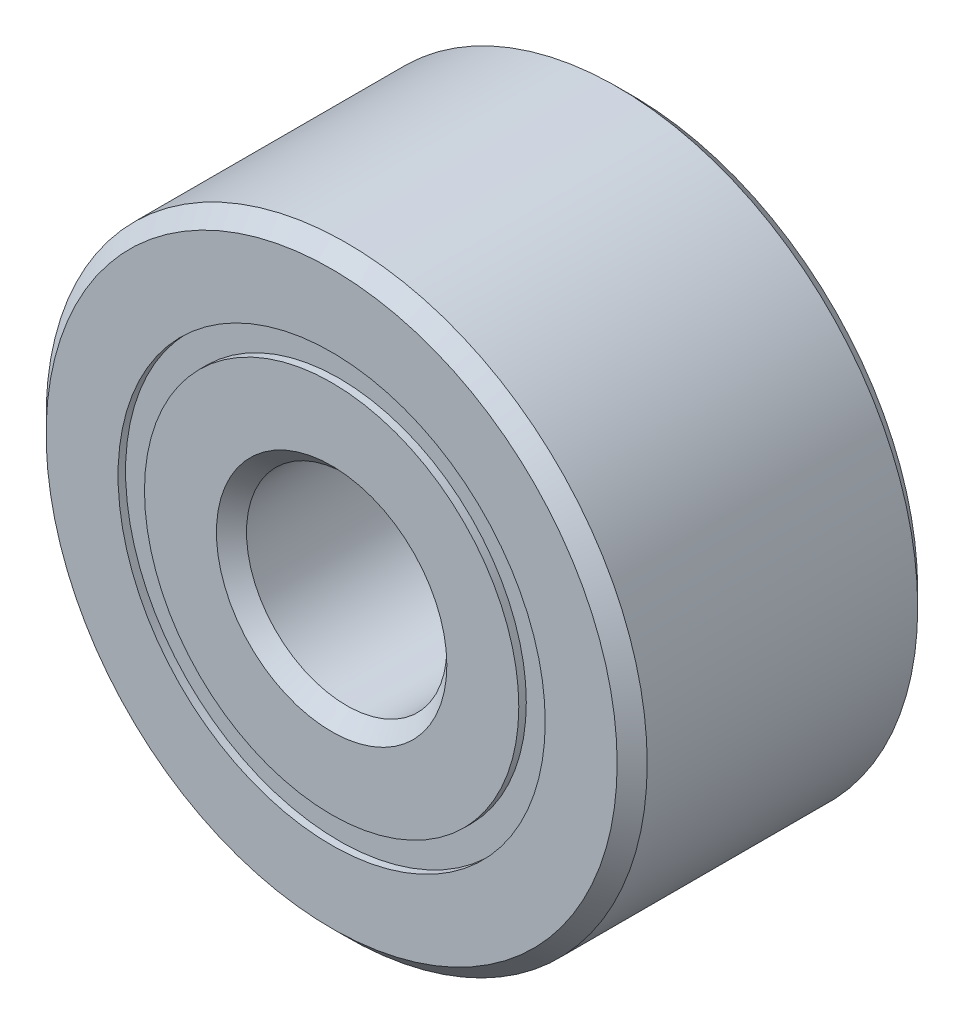
from build123d import *

# Parameters (mm, degrees)
CIRPATTERN1_COUNT = 12
SKETCH5_W         = 0.745416562
SKETCH5_H         = 0.263736264


with BuildPart() as part:
    # Sketch1 → Revolve1 (revolve)
    with BuildSketch(Plane(origin=(0, 0, 0), x_dir=(0, 0, -1), z_dir=(1, 0, 0))):
        with BuildLine():
            Line((1.35, 3), (-1.35, 3))
            Line((-1.35, 3), (-1.5, 2.85))
            Line((-1.5, 2.85), (-1.5, 2.131868132))
            Line((-1.5, 2.131868132), (-0.666666667, 2.131868132))
            ThreePointArc((-0.666666667, 2.131868132), (0, 2.679583438), (0.666666667, 2.131868132))
            Line((0.666666667, 2.131868132), (1.5, 2.131868132))
            Line((1.5, 2.131868132), (1.5, 2.85))
            Line((1.5, 2.85), (1.35, 3))
        make_face()
    revolve(axis=Axis((0, 0, 1.5), (0, 0, -1)))


with BuildPart() as body_2:
    # Sketch3 → Revolve3 (revolve)
    with BuildSketch(Plane(origin=(0, 0, 0), x_dir=(0, 0, -1), z_dir=(1, 0, 0))):
        with BuildLine():
            Line((-1.5, 1.868131868), (-0.666666667, 1.868131868))
            ThreePointArc((-0.666666667, 1.868131868), (0, 1.320416562), (0.666666667, 1.868131868))
            Line((0.666666667, 1.868131868), (1.5, 1.868131868))
            Line((1.5, 1.868131868), (1.5, 1.15))
            Line((1.5, 1.15), (1.35, 1))
            Line((1.35, 1), (-1.35, 1))
            Line((-1.35, 1), (-1.5, 1.15))
            Line((-1.5, 1.15), (-1.5, 1.868131868))
        make_face()
    revolve(axis=Axis((0, 0, 1.5), (0, 0, -1)))


with BuildPart() as body_3:
    # Sketch4 → Revolve4 (revolve)
    with BuildSketch(Plane(origin=(0, 0, 0), x_dir=(0, 0, -1), z_dir=(1, 0, 0))):
        with BuildLine():
            Line((-0.679583438, 2), (0.679583438, 2))
            ThreePointArc((0.679583438, 2), (0, 2.679583438), (-0.679583438, 2))
        make_face()
    revolve(axis=Axis((0, 2, 0.679583438), (0, 0, -1)))


with BuildPart() as cirpattern1_1:
    # CirPattern1: pattern copy
    add(body_3.part.rotate(Axis((0, 0, 0), (0, 0, 1)), 1 * 360 / CIRPATTERN1_COUNT))


with BuildPart() as cirpattern1_2:
    # CirPattern1: pattern copy
    add(body_3.part.rotate(Axis((0, 0, 0), (0, 0, 1)), 2 * 360 / CIRPATTERN1_COUNT))


with BuildPart() as cirpattern1_3:
    # CirPattern1: pattern copy
    add(body_3.part.rotate(Axis((0, 0, 0), (0, 0, 1)), 3 * 360 / CIRPATTERN1_COUNT))


with BuildPart() as cirpattern1_4:
    # CirPattern1: pattern copy
    add(body_3.part.rotate(Axis((0, 0, 0), (0, 0, 1)), 4 * 360 / CIRPATTERN1_COUNT))


with BuildPart() as cirpattern1_5:
    # CirPattern1: pattern copy
    add(body_3.part.rotate(Axis((0, 0, 0), (0, 0, 1)), 5 * 360 / CIRPATTERN1_COUNT))


with BuildPart() as cirpattern1_6:
    # CirPattern1: pattern copy
    add(body_3.part.rotate(Axis((0, 0, 0), (0, 0, 1)), 6 * 360 / CIRPATTERN1_COUNT))


with BuildPart() as cirpattern1_7:
    # CirPattern1: pattern copy
    add(body_3.part.rotate(Axis((0, 0, 0), (0, 0, 1)), 7 * 360 / CIRPATTERN1_COUNT))


with BuildPart() as cirpattern1_8:
    # CirPattern1: pattern copy
    add(body_3.part.rotate(Axis((0, 0, 0), (0, 0, 1)), 8 * 360 / CIRPATTERN1_COUNT))


with BuildPart() as cirpattern1_9:
    # CirPattern1: pattern copy
    add(body_3.part.rotate(Axis((0, 0, 0), (0, 0, 1)), 9 * 360 / CIRPATTERN1_COUNT))


with BuildPart() as cirpattern1_10:
    # CirPattern1: pattern copy
    add(body_3.part.rotate(Axis((0, 0, 0), (0, 0, 1)), 10 * 360 / CIRPATTERN1_COUNT))


with BuildPart() as cirpattern1_11:
    # CirPattern1: pattern copy
    add(body_3.part.rotate(Axis((0, 0, 0), (0, 0, 1)), 11 * 360 / CIRPATTERN1_COUNT))


with BuildPart() as body_15:
    # Sketch5 → Revolve5 (revolve)
    with BuildSketch(Plane(origin=(0, 0, 0), x_dir=(0, 0, -1), z_dir=(1, 0, 0))):
        with Locations((-1.052291719, 2)):
            Rectangle(SKETCH5_W, SKETCH5_H)
        with Locations((1.052291719, 2)):
            Rectangle(SKETCH5_W, SKETCH5_H)
    revolve(axis=Axis((0, 0, 1.5), (0, 0, -1)))


solid = Compound([part.part, body_2.part, body_3.part, cirpattern1_1.part, cirpattern1_2.part, cirpattern1_3.part, cirpattern1_4.part, cirpattern1_5.part, cirpattern1_6.part, cirpattern1_7.part, cirpattern1_8.part, cirpattern1_9.part, cirpattern1_10.part, cirpattern1_11.part, body_15.part])
